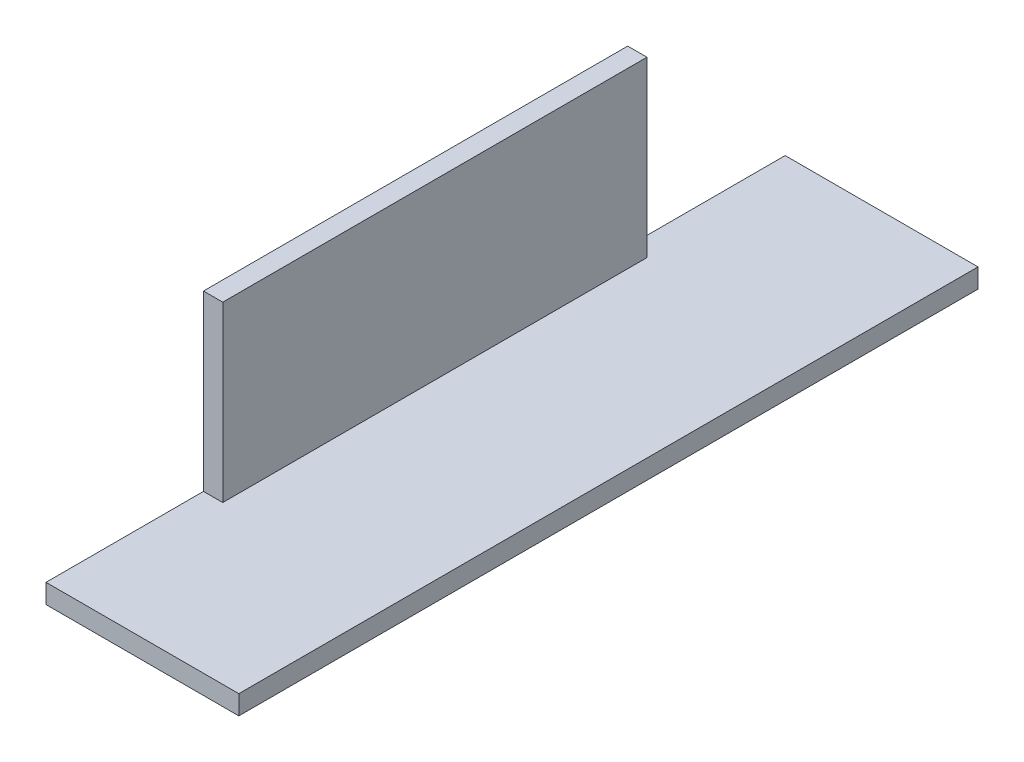
from build123d import *

# Parameters (mm, degrees)
EXTRUDE_1_DEPTH     = 115
SKETCH_2_W          = 24.5
SKETCH_2_H          = 27
CUT_EXTRUDE_1_DEPTH = 31


with BuildPart() as part:
    # Эскиз1 → Бобышка-Вытянуть1 (new body)
    with BuildSketch(Plane.XY):
        Polygon((0, 30), (0, 0), (30, 0), (30, 3), (3, 3), (3, 30), align=None)
    extrude(amount=EXTRUDE_1_DEPTH)

    # Эскиз2 → Вырез-Вытянуть1 (cut, through all)
    with BuildSketch(Plane.ZY):
        with Locations((12.25, 16.5)):
            Rectangle(SKETCH_2_W, SKETCH_2_H)
        with Locations((102.75, 16.5)):
            Rectangle(SKETCH_2_W, SKETCH_2_H)
    extrude(amount=-CUT_EXTRUDE_1_DEPTH, mode=Mode.SUBTRACT)


solid = part.part
